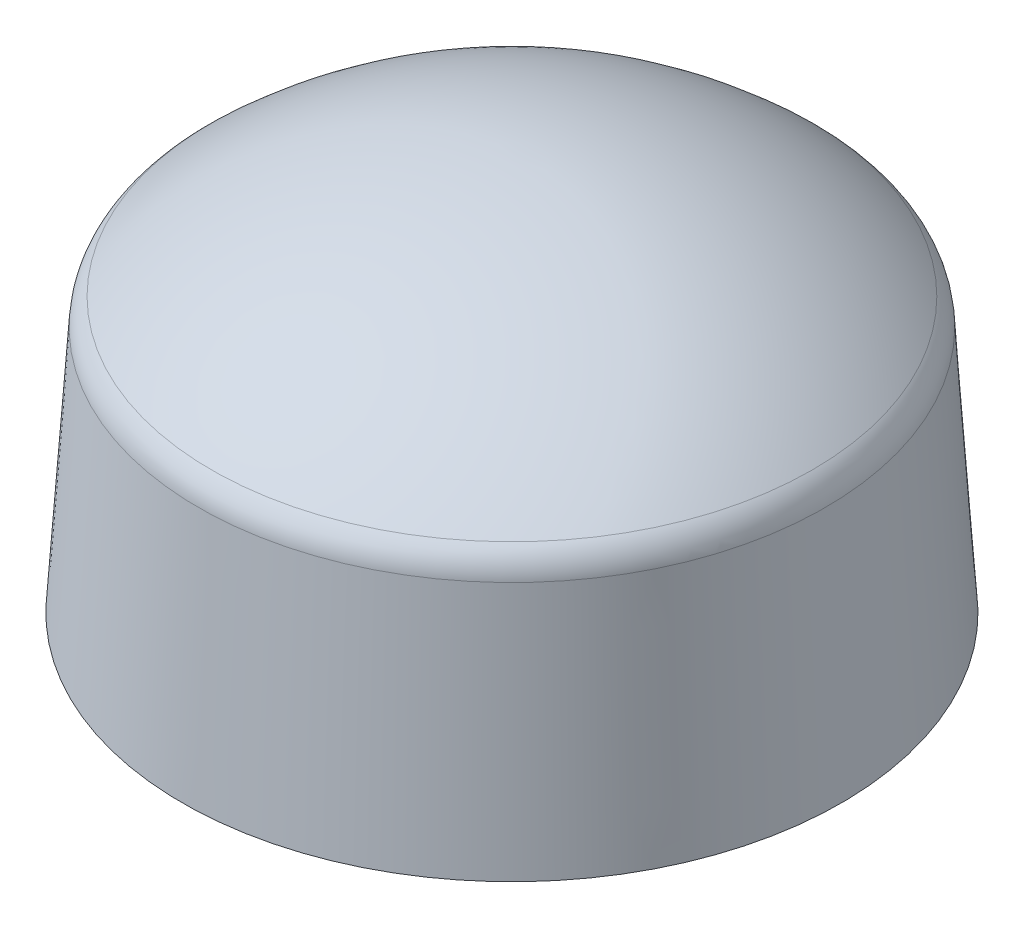
from build123d import *


with BuildPart() as part:
    # Sketch1 → Revolve1 (revolve)
    with BuildSketch(Plane.XY):
        with BuildLine():
            Line((-7.990929537, -3.644388375), (-8.41, -9.96))
            Line((-8.41, -9.96), (-6.89, -9.96))
            Line((-6.89, -9.96), (-6.79, -9.96))
            Line((-6.79, -9.96), (-6.79, -9.46))
            Line((-6.79, -9.46), (-7.29, -9.46))
            Line((-7.29, -9.46), (-6.934045173, -4.095574106))
            ThreePointArc((-6.934045173, -4.095574106), (-6.919243429, -4.038745871), (-6.884556501, -3.991360674))
            ThreePointArc((-6.884556501, -3.991360674), (-3.699614673, -1.98226408), (0, -1.28))
            Line((0, -1.28), (0, 0))
            ThreePointArc((0, 0), (-4.111446691, -0.768945317), (-7.667085246, -2.971830982))
            ThreePointArc((-7.667085246, -2.971830982), (-7.894114775, -3.276759708), (-7.990929537, -3.644388375))
        make_face()
    revolve(axis=Axis((0, 0, 0), (0, 1, 0)))


solid = part.part
